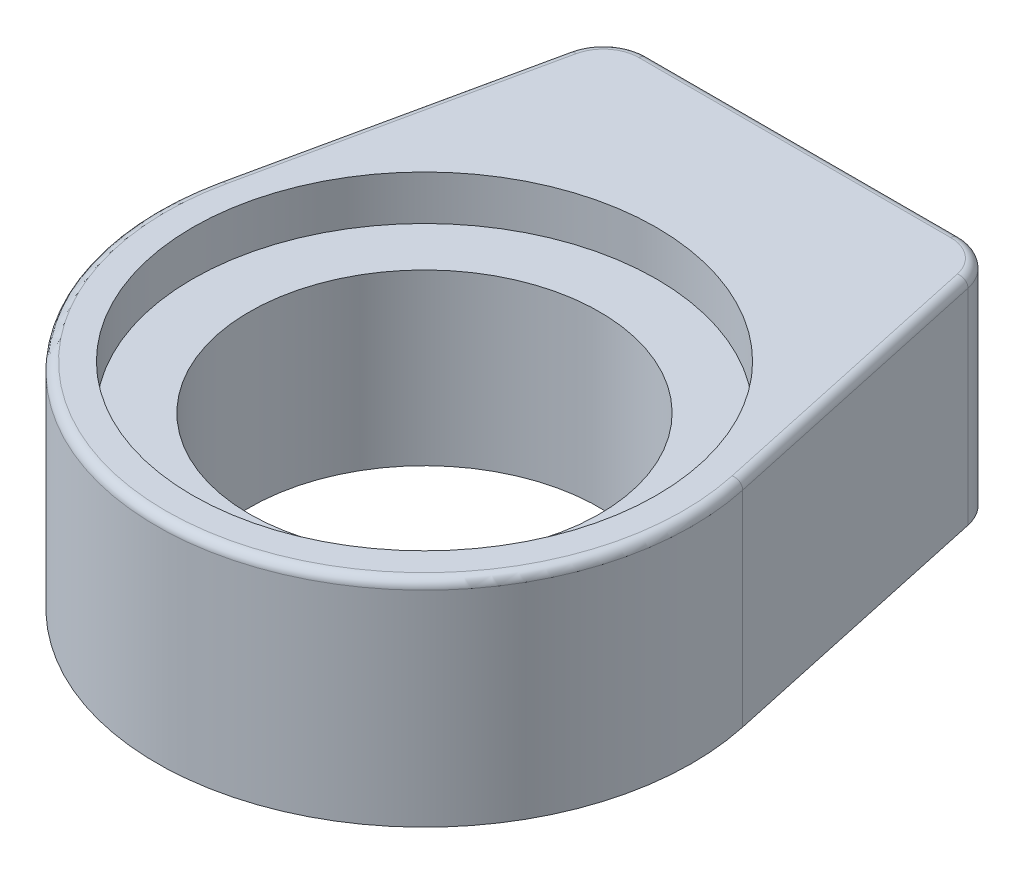
from build123d import *

# Parameters (mm, degrees)
EXTRUDE1_DEPTH = 12.192
FILLET2_R      = 2.54
FILLET1_R      = 0.508
SKETCH6_R      = 9.9695
EXTRUDE2_DEPTH = 13.192
SKETCH7_R      = 13.208
EXTRUDE3_DEPTH = 2.54


with BuildPart() as part:
    # Sketch5 → Extrude1 (new body)
    with BuildSketch(Plane(origin=(0, 0, 0), x_dir=(1, 0, 0), z_dir=(0, 1, 0))):
        with BuildLine():
            Line((-10.922, 21.59), (10.922, 21.59))
            Line((10.922, 21.59), (14.895447762, 3.222302897))
            ThreePointArc((14.895447762, 3.222302897), (0, -15.24), (-14.895447762, 3.222302897))
            Line((-14.895447762, 3.222302897), (-10.922, 21.59))
        make_face()
    extrude(amount=EXTRUDE1_DEPTH)

    # Fillet2
    fillet2_edges = [part.edges().sort_by_distance(p)[0] for p in [
        (-10.922, 6.096, -21.59),
        (10.922, 6.096, -21.59),
    ]]
    fillet(fillet2_edges, radius=FILLET2_R)

    # Fillet1
    fillet1_edges = [part.edges().sort_by_distance(p)[0] for p in [
        (13.125370945, 12.192, -11.40467669),
        (-13.125370945, 12.192, -11.40467669),
        (0, 12.192, -21.59),
        (10.467632001, 12.192, -21.026829308),
        (-10.467632001, 12.192, -21.026829308),
        (0, 12.192, 15.24),
    ]]
    fillet(fillet1_edges, radius=FILLET1_R)

    # Sketch6 → Extrude2 (cut, through all)
    with BuildSketch(Plane(origin=(0, 12.192, 0), x_dir=(1, 0, 0), z_dir=(0, 1, 0))):
        Circle(SKETCH6_R)
    extrude(amount=-EXTRUDE2_DEPTH, mode=Mode.SUBTRACT)

    # Sketch7 → Extrude3 (cut)
    with BuildSketch(Plane(origin=(0, 12.192, 0), x_dir=(1, 0, 0), z_dir=(0, 1, 0))):
        Circle(SKETCH7_R)
    extrude(amount=-EXTRUDE3_DEPTH, mode=Mode.SUBTRACT)


solid = part.part
